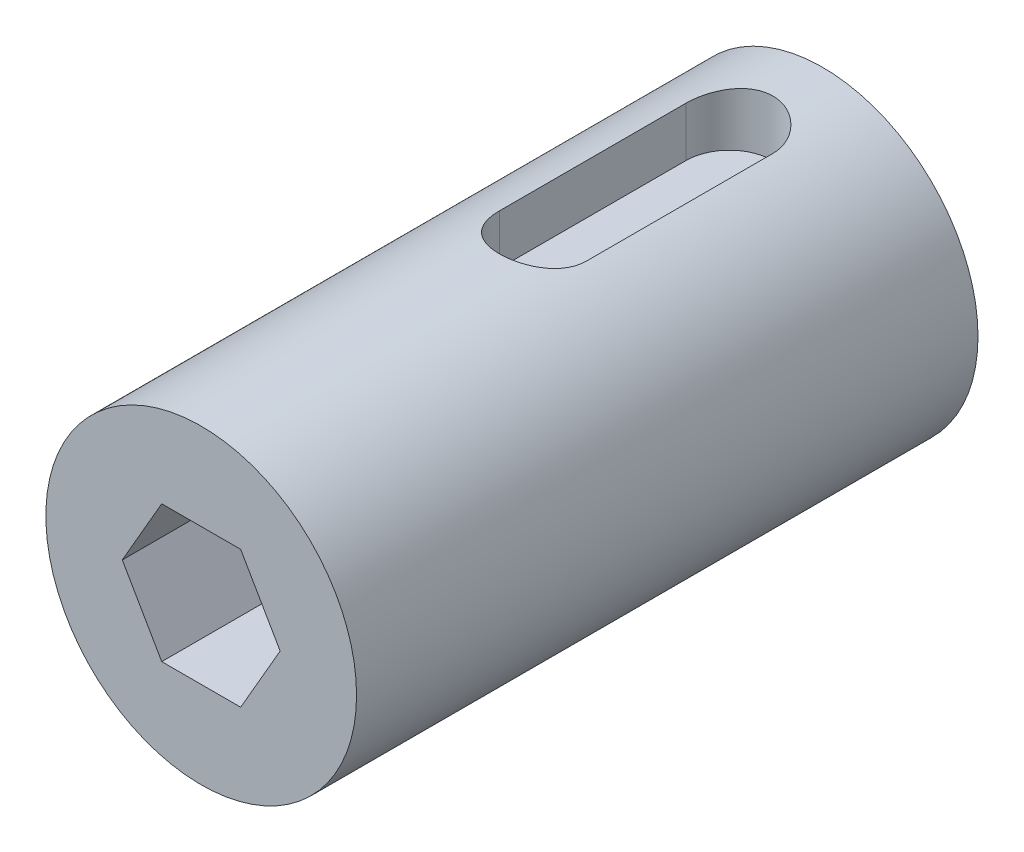
from build123d import *

# Parameters (mm, degrees)
SCHIZZO1_R                   = 12.5
ESTRUSIONE_ESTRUSIONE1_DEPTH = 50
TAGLIO_ESTRUSIONE1_DEPTH     = 15
TAGLIO_ESTRUSIONE3_START     = 23
TAGLIO_ESTRUSIONE3_DEPTH     = 15


with BuildPart() as part:
    # Schizzo1 → Estrusione-Estrusione1 (new body)
    with BuildSketch(Plane.XY):
        Circle(SCHIZZO1_R)
    extrude(amount=ESTRUSIONE_ESTRUSIONE1_DEPTH)

    # Schizzo2 → Taglio-Estrusione1 (cut)
    with BuildSketch(Plane.XY.offset(50)):
        Polygon((-3.175426481, 5.5), (-6.350852961, 0), (-3.175426481, -5.5), (3.175426481, -5.5), (6.350852961, 0), (3.175426481, 5.5), align=None)
    extrude(amount=-TAGLIO_ESTRUSIONE1_DEPTH, mode=Mode.SUBTRACT)

    # Schizzo3 → Taglio-Estrusione3 (cut)
    with BuildSketch(Plane(origin=(0, 0, 0), x_dir=(1, 0, 0), z_dir=(0, 1, 0)).offset(TAGLIO_ESTRUSIONE3_START)):
        with BuildLine():
            Line((3.5, -7.5), (3.5, -22.5))
            ThreePointArc((3.5, -22.5), (0, -26), (-3.5, -22.5))
            Line((-3.5, -22.5), (-3.5, -7.5))
            ThreePointArc((-3.5, -7.5), (0, -4), (3.5, -7.5))
        make_face()
    extrude(amount=-TAGLIO_ESTRUSIONE3_DEPTH, mode=Mode.SUBTRACT)


solid = part.part
